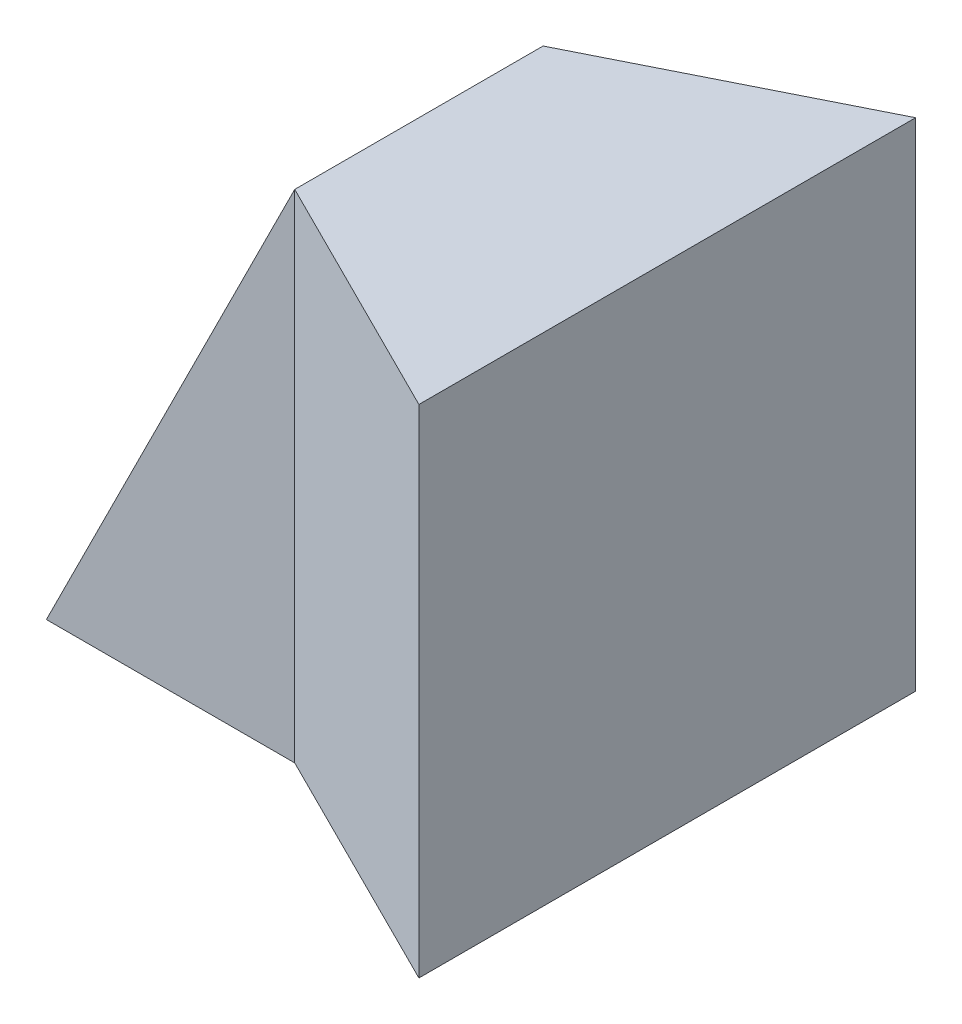
from build123d import *

# Parameters (mm, degrees)
SKETCH1_W           = 40
SKETCH1_H           = 40
BOSS_EXTRUDE1_DEPTH = 40
CUT_EXTRUDE1_DEPTH  = 40
SKETCH3_W           = 20
SKETCH3_H           = 10
CUT_EXTRUDE2_DEPTH  = 40


with BuildPart() as part:
    # Sketch1 → Boss-Extrude1 (new body)
    with BuildSketch(Plane.XY):
        with Locations((20, 20)):
            Rectangle(SKETCH1_W, SKETCH1_H)
    extrude(amount=BOSS_EXTRUDE1_DEPTH)

    # Sketch2 → Cut-Extrude1 (cut)
    with BuildSketch(Plane.XY.offset(40)):
        Polygon((0, 40), (20, 40), (0, 0), align=None)
    extrude(amount=-CUT_EXTRUDE1_DEPTH, mode=Mode.SUBTRACT)

    # Sketch3 → Cut-Extrude2 (cut)
    with BuildSketch(Plane.XZ):
        with Locations((10, 5)):
            Rectangle(SKETCH3_W, SKETCH3_H)
        Polygon((40, 0), (20, 10), (20, 0), align=None)
        with Locations((10, 35)):
            Rectangle(SKETCH3_W, SKETCH3_H)
        Polygon((20, 40), (20, 30), (40, 40), align=None)
    extrude(amount=-CUT_EXTRUDE2_DEPTH, mode=Mode.SUBTRACT)


solid = part.part
